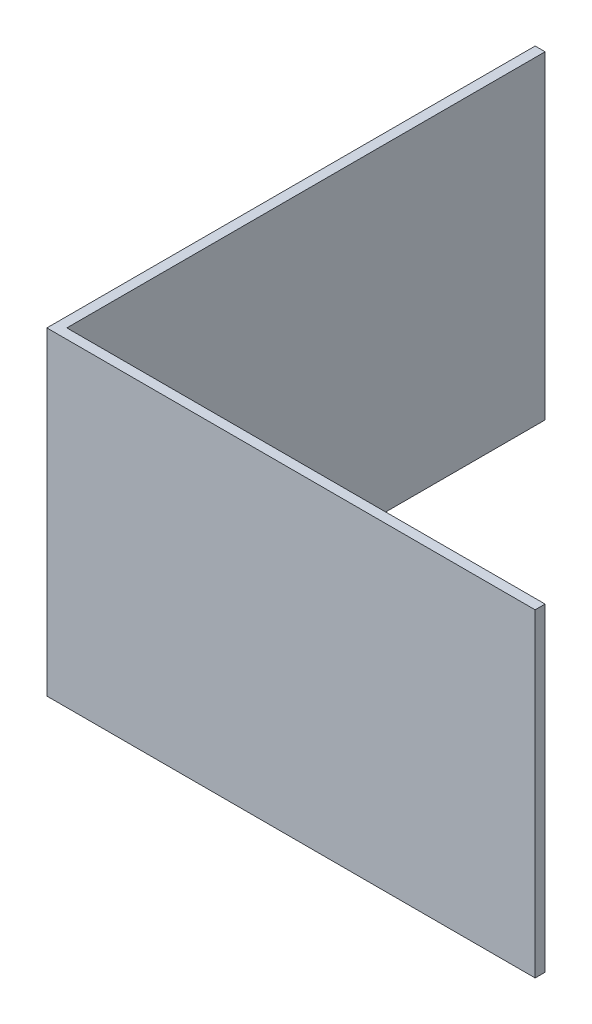
from build123d import *

# Parameters (mm, degrees)
BOSS_EXTRUDE1_DEPTH = 50.8


with BuildPart() as part:
    # Sketch1 → Boss-Extrude1 (new body)
    with BuildSketch(Plane(origin=(0, 0, 0), x_dir=(1, 0, 0), z_dir=(0, 1, 0))):
        Polygon((-38.89375, -38.89375), (38.89375, -38.89375), (38.89375, -37.30625), (-37.30625, -37.30625), (-37.30625, 38.89375), (-38.89375, 38.89375), align=None)
    extrude(amount=BOSS_EXTRUDE1_DEPTH)


solid = part.part
